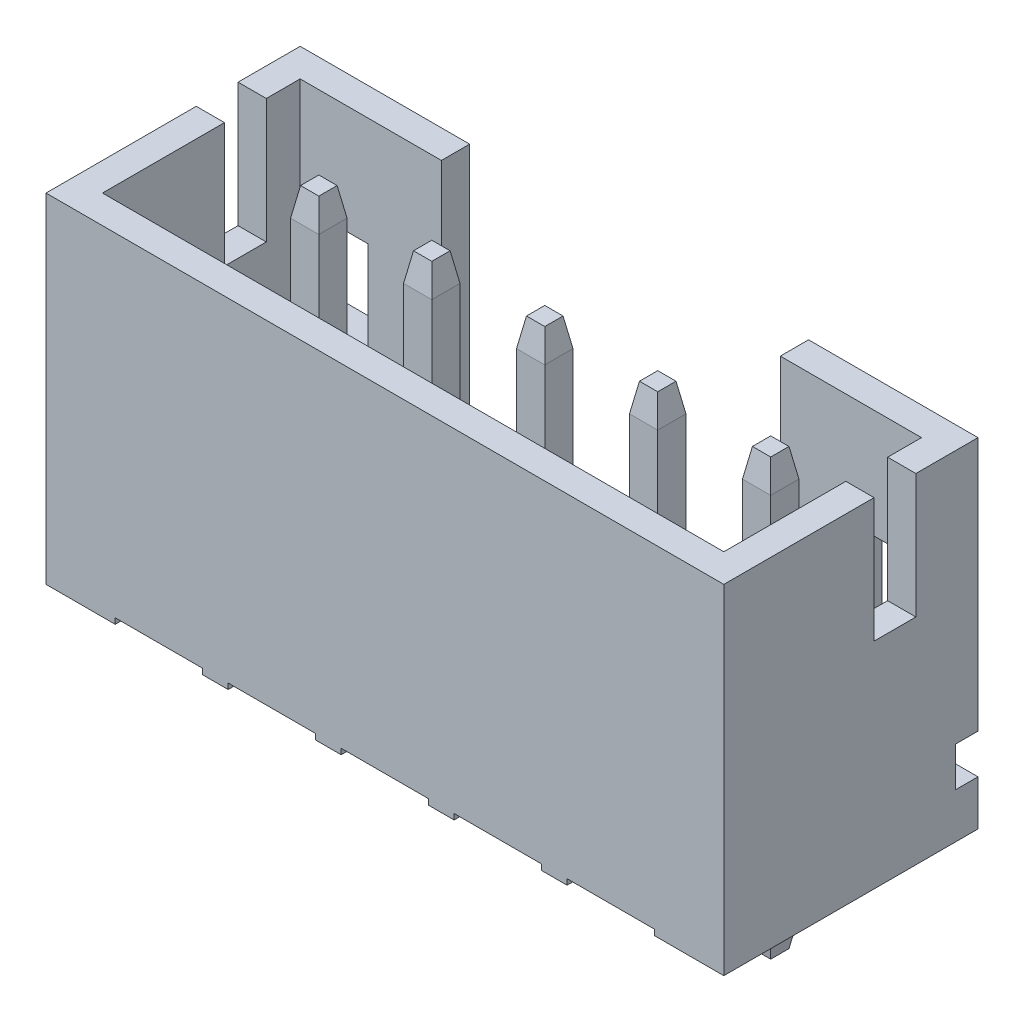
from build123d import *

# Parameters (mm, degrees)
SKETCH1_W               = 12
SKETCH1_H               = 4.5
EXTRUDE1_DEPTH          = 6
CUT_EXTRUDE1_DEPTH      = 5.5
SKETCH3_W               = 11
SKETCH3_H               = 3.5
CUT_EXTRUDE2_DEPTH      = 4.2
SKETCH5_W               = 0.74
SKETCH5_H               = 2.2
CUT_EXTRUDE3_DEPTH      = 13
SKETCH6_W               = 6
SKETCH6_H               = 4
CUT_EXTRUDE4_DEPTH      = 1.2
SKETCH9_W               = 0.4
SKETCH9_H               = 0.7
CUT_EXTRUDE5_DEPTH      = 7
CUT_EXTRUDE5_DEPTH_BACK = 7
SKETCH10_W              = 1.2
SKETCH10_H              = 1.6
CUT_EXTRUDE6_DEPTH      = 0.5
CUT_EXTRUDE7_START      = -5.5
CUT_EXTRUDE7_DEPTH      = 11
LPATTERN4_COUNT         = 3
LPATTERN4_PITCH         = 2
LPATTERN4_COL_COUNT     = 3
LPATTERN4_COL_PITCH     = 2
EXTRUDE2_START          = -2
EXTRUDE2_DEPTH          = 7.7
LPATTERN2_COUNT         = 3
LPATTERN2_PITCH         = 2
LPATTERN2_COL_COUNT     = 3
LPATTERN2_COL_PITCH     = 2
CHAMFER1_SIZE           = 0.5
CHAMFER1_SIZE2          = 0.08816349
CHAMFER1_PART_2_SIZE    = 0.5
CHAMFER1_PART_2_SIZE2   = 0.08816349
CHAMFER1_PART_3_SIZE    = 0.5
CHAMFER1_PART_3_SIZE2   = 0.08816349
CHAMFER1_PART_4_SIZE    = 0.5
CHAMFER1_PART_4_SIZE2   = 0.08816349
CHAMFER1_PART_5_SIZE    = 0.5
CHAMFER1_PART_5_SIZE2   = 0.08816349
CHAMFER1_PART_6_SIZE    = 0.5
CHAMFER1_PART_6_SIZE2   = 0.08816349
CHAMFER1_PART_7_SIZE    = 0.5
CHAMFER1_PART_7_SIZE2   = 0.08816349
CHAMFER1_PART_8_SIZE    = 0.5
CHAMFER1_PART_8_SIZE2   = 0.08816349
CHAMFER1_PART_9_SIZE    = 0.5
CHAMFER1_PART_9_SIZE2   = 0.08816349
CHAMFER1_PART_10_SIZE   = 0.5
CHAMFER1_PART_10_SIZE2  = 0.08816349
CHAMFER1_PART_11_SIZE   = 0.5
CHAMFER1_PART_11_SIZE2  = 0.08816349
CHAMFER1_PART_12_SIZE   = 0.5
CHAMFER1_PART_12_SIZE2  = 0.08816349
CHAMFER1_PART_13_SIZE   = 0.5
CHAMFER1_PART_13_SIZE2  = 0.08816349
CHAMFER1_PART_14_SIZE   = 0.5
CHAMFER1_PART_14_SIZE2  = 0.08816349
CHAMFER1_PART_15_SIZE   = 0.5
CHAMFER1_PART_15_SIZE2  = 0.08816349
CHAMFER1_PART_16_SIZE   = 0.5
CHAMFER1_PART_16_SIZE2  = 0.08816349
CHAMFER1_PART_17_SIZE   = 0.5
CHAMFER1_PART_17_SIZE2  = 0.08816349
CHAMFER1_PART_18_SIZE   = 0.5
CHAMFER1_PART_18_SIZE2  = 0.08816349
CHAMFER1_PART_19_SIZE   = 0.5
CHAMFER1_PART_19_SIZE2  = 0.08816349
CHAMFER1_PART_20_SIZE   = 0.5
CHAMFER1_PART_20_SIZE2  = 0.08816349
CHAMFER1_PART_21_SIZE   = 0.5
CHAMFER1_PART_21_SIZE2  = 0.08816349
CHAMFER1_PART_22_SIZE   = 0.5
CHAMFER1_PART_22_SIZE2  = 0.08816349
CHAMFER1_PART_23_SIZE   = 0.5
CHAMFER1_PART_23_SIZE2  = 0.08816349
CHAMFER1_PART_24_SIZE   = 0.5
CHAMFER1_PART_24_SIZE2  = 0.08816349
CHAMFER1_PART_25_SIZE   = 0.5
CHAMFER1_PART_25_SIZE2  = 0.08816349
CHAMFER1_PART_26_SIZE   = 0.5
CHAMFER1_PART_26_SIZE2  = 0.08816349
CHAMFER1_PART_27_SIZE   = 0.5
CHAMFER1_PART_27_SIZE2  = 0.08816349
CHAMFER1_PART_28_SIZE   = 0.5
CHAMFER1_PART_28_SIZE2  = 0.08816349
CHAMFER1_PART_29_SIZE   = 0.5
CHAMFER1_PART_29_SIZE2  = 0.08816349
CHAMFER1_PART_30_SIZE   = 0.5
CHAMFER1_PART_30_SIZE2  = 0.08816349
CHAMFER1_PART_31_SIZE   = 0.5
CHAMFER1_PART_31_SIZE2  = 0.08816349
CHAMFER1_PART_32_SIZE   = 0.5
CHAMFER1_PART_32_SIZE2  = 0.08816349
CHAMFER1_PART_33_SIZE   = 0.5
CHAMFER1_PART_33_SIZE2  = 0.08816349
CHAMFER1_PART_34_SIZE   = 0.5
CHAMFER1_PART_34_SIZE2  = 0.08816349
CHAMFER1_PART_35_SIZE   = 0.5
CHAMFER1_PART_35_SIZE2  = 0.08816349
CHAMFER1_PART_36_SIZE   = 0.5
CHAMFER1_PART_36_SIZE2  = 0.08816349
CHAMFER1_PART_37_SIZE   = 0.5
CHAMFER1_PART_37_SIZE2  = 0.08816349
CHAMFER1_PART_38_SIZE   = 0.5
CHAMFER1_PART_38_SIZE2  = 0.08816349
CHAMFER1_PART_39_SIZE   = 0.5
CHAMFER1_PART_39_SIZE2  = 0.08816349
CHAMFER1_PART_40_SIZE   = 0.5
CHAMFER1_PART_40_SIZE2  = 0.08816349


with BuildPart() as part:
    # Sketch1 → Extrude1 (new body)
    with BuildSketch(Plane(origin=(0, 0, 0), x_dir=(1, 0, 0), z_dir=(0, 1, 0))):
        Rectangle(SKETCH1_W, SKETCH1_H)
    extrude(amount=EXTRUDE1_DEPTH)

    # Sketch2 → Cut-Extrude1 (cut, through all)
    with BuildSketch(Plane.XY.offset(2.25)):
        Polygon((-0.775, 0.1), (0.775, 0.1), (0.775, 0), (0, 0), (-0.775, 0), align=None)
    cut_extrude1 = extrude(amount=-CUT_EXTRUDE1_DEPTH, mode=Mode.SUBTRACT)

    # Sketch3 → Cut-Extrude2 (cut)
    with BuildSketch(Plane(origin=(0, 6, 0), x_dir=(-1, 0, 0), z_dir=(0, 1, 0))):
        Rectangle(SKETCH3_W, SKETCH3_H)
    extrude(amount=-CUT_EXTRUDE2_DEPTH, mode=Mode.SUBTRACT)

    # Sketch5 → Cut-Extrude3 (cut, through all)
    with BuildSketch(Plane.ZY.offset(6)):
        with Locations((-0.78, 4.9)):
            Rectangle(SKETCH5_W, SKETCH5_H)
    extrude(amount=-CUT_EXTRUDE3_DEPTH, mode=Mode.SUBTRACT)

    # Sketch6 → Cut-Extrude4 (cut)
    with BuildSketch(Plane(origin=(0, 0, -2.25), x_dir=(-1, 0, 0), z_dir=(0, 0, -1))):
        with Locations((0, 4)):
            Rectangle(SKETCH6_W, SKETCH6_H)
    extrude(amount=-CUT_EXTRUDE4_DEPTH, mode=Mode.SUBTRACT)

    # Sketch9 → Cut-Extrude5 (cut, two sides)
    with BuildSketch(Plane(origin=(0, 0, 0), x_dir=(0, 0, -1), z_dir=(1, 0, 0))) as cut_extrude5_sk:
        with Locations((2.05, 1.15)):
            Rectangle(SKETCH9_W, SKETCH9_H)
    extrude(amount=CUT_EXTRUDE5_DEPTH, mode=Mode.SUBTRACT)
    extrude(cut_extrude5_sk.sketch, amount=-CUT_EXTRUDE5_DEPTH_BACK, mode=Mode.SUBTRACT)

    # Sketch10 → Cut-Extrude6 (cut)
    with BuildSketch(Plane(origin=(0, 0, -2.25), x_dir=(-1, 0, 0), z_dir=(0, 0, -1))):
        with Locations((-4.9, 3.271645398)):
            Rectangle(SKETCH10_W, SKETCH10_H)
        with Locations((4.9, 3.271645398)):
            Rectangle(SKETCH10_W, SKETCH10_H)
    extrude(amount=-CUT_EXTRUDE6_DEPTH, mode=Mode.SUBTRACT)

    # Sketch11 → Cut-Extrude7 (cut)
    with BuildSketch(Plane(origin=(0, 0, 0), x_dir=(0, 0, -1), z_dir=(1, 0, 0)).offset(CUT_EXTRUDE7_START)):
        Polygon((0, 1.8), (-0.576387184, 1.223612816), (-1.75, 1.223612816), (-1.75, 1.8), align=None)
    extrude(amount=CUT_EXTRUDE7_DEPTH, mode=Mode.SUBTRACT)

    # LPattern4: Cut-Extrude1 ×3
    with Locations(*[(i * LPATTERN4_PITCH, 0, 0) for i in range(1, LPATTERN4_COUNT)]):
        add(cut_extrude1, mode=Mode.SUBTRACT)

    # LPattern4 col: Cut-Extrude1 ×3
    with Locations(*[(-i * LPATTERN4_COL_PITCH, 0, 0) for i in range(1, LPATTERN4_COL_COUNT)]):
        add(cut_extrude1, mode=Mode.SUBTRACT)

    # Sketch7 → Extrude2 (add)
    with BuildSketch(Plane(origin=(0, 0, 0), x_dir=(1, 0, 0), z_dir=(0, 1, 0)).offset(EXTRUDE2_START)):
        Polygon((0, 0.33), (0.25, 0.33), (0.25, 0.83), (-0.25, 0.83), (-0.25, 0.33), align=None)
    extrude2 = extrude(amount=EXTRUDE2_DEPTH)

    # LPattern2: Extrude2 ×3
    with Locations(*[(i * LPATTERN2_PITCH, 0, 0) for i in range(1, LPATTERN2_COUNT)]):
        add(extrude2)

    # LPattern2 col: Extrude2 ×3
    with Locations(*[(-i * LPATTERN2_COL_PITCH, 0, 0) for i in range(1, LPATTERN2_COL_COUNT)]):
        add(extrude2)

    # Chamfer1
    chamfer1_edges = [part.edges().sort_by_distance(p)[0] for p in [
        (-0.25, -2, -0.58),
    ]]
    chamfer1_side = [part.faces().sort_by_distance(p)[0] for p in [
        (-0.25, -0.95, -0.58),
    ]]
    chamfer(chamfer1_edges, length=CHAMFER1_SIZE, length2=CHAMFER1_SIZE2, reference=chamfer1_side[0])

    # Chamfer1 part 2
    chamfer1_part_2_edges = [part.edges().sort_by_distance(p)[0] for p in [
        (0, -2, -0.33),
    ]]
    chamfer1_part_2_side = [part.faces().sort_by_distance(p)[0] for p in [
        (0, -0.95, -0.33),
    ]]
    chamfer(chamfer1_part_2_edges, length=CHAMFER1_PART_2_SIZE, length2=CHAMFER1_PART_2_SIZE2, reference=chamfer1_part_2_side[0])

    # Chamfer1 part 3
    chamfer1_part_3_edges = [part.edges().sort_by_distance(p)[0] for p in [
        (0.25, -2, -0.58),
    ]]
    chamfer1_part_3_side = [part.faces().sort_by_distance(p)[0] for p in [
        (0.25, -0.95, -0.58),
    ]]
    chamfer(chamfer1_part_3_edges, length=CHAMFER1_PART_3_SIZE, length2=CHAMFER1_PART_3_SIZE2, reference=chamfer1_part_3_side[0])

    # Chamfer1 part 4
    chamfer1_part_4_edges = [part.edges().sort_by_distance(p)[0] for p in [
        (0, -2, -0.83),
    ]]
    chamfer1_part_4_side = [part.faces().sort_by_distance(p)[0] for p in [
        (0, -0.95, -0.83),
    ]]
    chamfer(chamfer1_part_4_edges, length=CHAMFER1_PART_4_SIZE, length2=CHAMFER1_PART_4_SIZE2, reference=chamfer1_part_4_side[0])

    # Chamfer1 part 5
    chamfer1_part_5_edges = [part.edges().sort_by_distance(p)[0] for p in [
        (0, 5.7, -0.83),
    ]]
    chamfer1_part_5_side = [part.faces().sort_by_distance(p)[0] for p in [
        (0, 3.75, -0.83),
    ]]
    chamfer(chamfer1_part_5_edges, length=CHAMFER1_PART_5_SIZE, length2=CHAMFER1_PART_5_SIZE2, reference=chamfer1_part_5_side[0])

    # Chamfer1 part 6
    chamfer1_part_6_edges = [part.edges().sort_by_distance(p)[0] for p in [
        (-0.25, 5.7, -0.58),
    ]]
    chamfer1_part_6_side = [part.faces().sort_by_distance(p)[0] for p in [
        (-0.25, 3.75, -0.58),
    ]]
    chamfer(chamfer1_part_6_edges, length=CHAMFER1_PART_6_SIZE, length2=CHAMFER1_PART_6_SIZE2, reference=chamfer1_part_6_side[0])

    # Chamfer1 part 7
    chamfer1_part_7_edges = [part.edges().sort_by_distance(p)[0] for p in [
        (0, 5.7, -0.33),
    ]]
    chamfer1_part_7_side = [part.faces().sort_by_distance(p)[0] for p in [
        (0, 3.75, -0.33),
    ]]
    chamfer(chamfer1_part_7_edges, length=CHAMFER1_PART_7_SIZE, length2=CHAMFER1_PART_7_SIZE2, reference=chamfer1_part_7_side[0])

    # Chamfer1 part 8
    chamfer1_part_8_edges = [part.edges().sort_by_distance(p)[0] for p in [
        (0.25, 5.7, -0.58),
    ]]
    chamfer1_part_8_side = [part.faces().sort_by_distance(p)[0] for p in [
        (0.25, 3.75, -0.58),
    ]]
    chamfer(chamfer1_part_8_edges, length=CHAMFER1_PART_8_SIZE, length2=CHAMFER1_PART_8_SIZE2, reference=chamfer1_part_8_side[0])

    # Chamfer1 part 9
    chamfer1_part_9_edges = [part.edges().sort_by_distance(p)[0] for p in [
        (-2.25, -2, -0.58),
    ]]
    chamfer1_part_9_side = [part.faces().sort_by_distance(p)[0] for p in [
        (-2.25, -0.95, -0.58),
    ]]
    chamfer(chamfer1_part_9_edges, length=CHAMFER1_PART_9_SIZE, length2=CHAMFER1_PART_9_SIZE2, reference=chamfer1_part_9_side[0])

    # Chamfer1 part 10
    chamfer1_part_10_edges = [part.edges().sort_by_distance(p)[0] for p in [
        (-2, -2, -0.33),
    ]]
    chamfer1_part_10_side = [part.faces().sort_by_distance(p)[0] for p in [
        (-2, -0.95, -0.33),
    ]]
    chamfer(chamfer1_part_10_edges, length=CHAMFER1_PART_10_SIZE, length2=CHAMFER1_PART_10_SIZE2, reference=chamfer1_part_10_side[0])

    # Chamfer1 part 11
    chamfer1_part_11_edges = [part.edges().sort_by_distance(p)[0] for p in [
        (-1.75, -2, -0.58),
    ]]
    chamfer1_part_11_side = [part.faces().sort_by_distance(p)[0] for p in [
        (-1.75, -0.95, -0.58),
    ]]
    chamfer(chamfer1_part_11_edges, length=CHAMFER1_PART_11_SIZE, length2=CHAMFER1_PART_11_SIZE2, reference=chamfer1_part_11_side[0])

    # Chamfer1 part 12
    chamfer1_part_12_edges = [part.edges().sort_by_distance(p)[0] for p in [
        (-2, -2, -0.83),
    ]]
    chamfer1_part_12_side = [part.faces().sort_by_distance(p)[0] for p in [
        (-2, -0.95, -0.83),
    ]]
    chamfer(chamfer1_part_12_edges, length=CHAMFER1_PART_12_SIZE, length2=CHAMFER1_PART_12_SIZE2, reference=chamfer1_part_12_side[0])

    # Chamfer1 part 13
    chamfer1_part_13_edges = [part.edges().sort_by_distance(p)[0] for p in [
        (-2, 5.7, -0.83),
    ]]
    chamfer1_part_13_side = [part.faces().sort_by_distance(p)[0] for p in [
        (-2, 3.75, -0.83),
    ]]
    chamfer(chamfer1_part_13_edges, length=CHAMFER1_PART_13_SIZE, length2=CHAMFER1_PART_13_SIZE2, reference=chamfer1_part_13_side[0])

    # Chamfer1 part 14
    chamfer1_part_14_edges = [part.edges().sort_by_distance(p)[0] for p in [
        (-2.25, 5.7, -0.58),
    ]]
    chamfer1_part_14_side = [part.faces().sort_by_distance(p)[0] for p in [
        (-2.25, 3.75, -0.58),
    ]]
    chamfer(chamfer1_part_14_edges, length=CHAMFER1_PART_14_SIZE, length2=CHAMFER1_PART_14_SIZE2, reference=chamfer1_part_14_side[0])

    # Chamfer1 part 15
    chamfer1_part_15_edges = [part.edges().sort_by_distance(p)[0] for p in [
        (-2, 5.7, -0.33),
    ]]
    chamfer1_part_15_side = [part.faces().sort_by_distance(p)[0] for p in [
        (-2, 3.75, -0.33),
    ]]
    chamfer(chamfer1_part_15_edges, length=CHAMFER1_PART_15_SIZE, length2=CHAMFER1_PART_15_SIZE2, reference=chamfer1_part_15_side[0])

    # Chamfer1 part 16
    chamfer1_part_16_edges = [part.edges().sort_by_distance(p)[0] for p in [
        (-1.75, 5.7, -0.58),
    ]]
    chamfer1_part_16_side = [part.faces().sort_by_distance(p)[0] for p in [
        (-1.75, 3.75, -0.58),
    ]]
    chamfer(chamfer1_part_16_edges, length=CHAMFER1_PART_16_SIZE, length2=CHAMFER1_PART_16_SIZE2, reference=chamfer1_part_16_side[0])

    # Chamfer1 part 17
    chamfer1_part_17_edges = [part.edges().sort_by_distance(p)[0] for p in [
        (-4.25, -2, -0.58),
    ]]
    chamfer1_part_17_side = [part.faces().sort_by_distance(p)[0] for p in [
        (-4.25, -0.95, -0.58),
    ]]
    chamfer(chamfer1_part_17_edges, length=CHAMFER1_PART_17_SIZE, length2=CHAMFER1_PART_17_SIZE2, reference=chamfer1_part_17_side[0])

    # Chamfer1 part 18
    chamfer1_part_18_edges = [part.edges().sort_by_distance(p)[0] for p in [
        (-4, -2, -0.33),
    ]]
    chamfer1_part_18_side = [part.faces().sort_by_distance(p)[0] for p in [
        (-4, -0.95, -0.33),
    ]]
    chamfer(chamfer1_part_18_edges, length=CHAMFER1_PART_18_SIZE, length2=CHAMFER1_PART_18_SIZE2, reference=chamfer1_part_18_side[0])

    # Chamfer1 part 19
    chamfer1_part_19_edges = [part.edges().sort_by_distance(p)[0] for p in [
        (-3.75, -2, -0.58),
    ]]
    chamfer1_part_19_side = [part.faces().sort_by_distance(p)[0] for p in [
        (-3.75, -0.95, -0.58),
    ]]
    chamfer(chamfer1_part_19_edges, length=CHAMFER1_PART_19_SIZE, length2=CHAMFER1_PART_19_SIZE2, reference=chamfer1_part_19_side[0])

    # Chamfer1 part 20
    chamfer1_part_20_edges = [part.edges().sort_by_distance(p)[0] for p in [
        (-4, -2, -0.83),
    ]]
    chamfer1_part_20_side = [part.faces().sort_by_distance(p)[0] for p in [
        (-4, -0.95, -0.83),
    ]]
    chamfer(chamfer1_part_20_edges, length=CHAMFER1_PART_20_SIZE, length2=CHAMFER1_PART_20_SIZE2, reference=chamfer1_part_20_side[0])

    # Chamfer1 part 21
    chamfer1_part_21_edges = [part.edges().sort_by_distance(p)[0] for p in [
        (-4, 5.7, -0.83),
    ]]
    chamfer1_part_21_side = [part.faces().sort_by_distance(p)[0] for p in [
        (-4, 3.75, -0.83),
    ]]
    chamfer(chamfer1_part_21_edges, length=CHAMFER1_PART_21_SIZE, length2=CHAMFER1_PART_21_SIZE2, reference=chamfer1_part_21_side[0])

    # Chamfer1 part 22
    chamfer1_part_22_edges = [part.edges().sort_by_distance(p)[0] for p in [
        (-4.25, 5.7, -0.58),
    ]]
    chamfer1_part_22_side = [part.faces().sort_by_distance(p)[0] for p in [
        (-4.25, 3.75, -0.58),
    ]]
    chamfer(chamfer1_part_22_edges, length=CHAMFER1_PART_22_SIZE, length2=CHAMFER1_PART_22_SIZE2, reference=chamfer1_part_22_side[0])

    # Chamfer1 part 23
    chamfer1_part_23_edges = [part.edges().sort_by_distance(p)[0] for p in [
        (-4, 5.7, -0.33),
    ]]
    chamfer1_part_23_side = [part.faces().sort_by_distance(p)[0] for p in [
        (-4, 3.75, -0.33),
    ]]
    chamfer(chamfer1_part_23_edges, length=CHAMFER1_PART_23_SIZE, length2=CHAMFER1_PART_23_SIZE2, reference=chamfer1_part_23_side[0])

    # Chamfer1 part 24
    chamfer1_part_24_edges = [part.edges().sort_by_distance(p)[0] for p in [
        (-3.75, 5.7, -0.58),
    ]]
    chamfer1_part_24_side = [part.faces().sort_by_distance(p)[0] for p in [
        (-3.75, 3.75, -0.58),
    ]]
    chamfer(chamfer1_part_24_edges, length=CHAMFER1_PART_24_SIZE, length2=CHAMFER1_PART_24_SIZE2, reference=chamfer1_part_24_side[0])

    # Chamfer1 part 25
    chamfer1_part_25_edges = [part.edges().sort_by_distance(p)[0] for p in [
        (1.75, -2, -0.58),
    ]]
    chamfer1_part_25_side = [part.faces().sort_by_distance(p)[0] for p in [
        (1.75, -0.95, -0.58),
    ]]
    chamfer(chamfer1_part_25_edges, length=CHAMFER1_PART_25_SIZE, length2=CHAMFER1_PART_25_SIZE2, reference=chamfer1_part_25_side[0])

    # Chamfer1 part 26
    chamfer1_part_26_edges = [part.edges().sort_by_distance(p)[0] for p in [
        (2, -2, -0.33),
    ]]
    chamfer1_part_26_side = [part.faces().sort_by_distance(p)[0] for p in [
        (2, -0.95, -0.33),
    ]]
    chamfer(chamfer1_part_26_edges, length=CHAMFER1_PART_26_SIZE, length2=CHAMFER1_PART_26_SIZE2, reference=chamfer1_part_26_side[0])

    # Chamfer1 part 27
    chamfer1_part_27_edges = [part.edges().sort_by_distance(p)[0] for p in [
        (2.25, -2, -0.58),
    ]]
    chamfer1_part_27_side = [part.faces().sort_by_distance(p)[0] for p in [
        (2.25, -0.95, -0.58),
    ]]
    chamfer(chamfer1_part_27_edges, length=CHAMFER1_PART_27_SIZE, length2=CHAMFER1_PART_27_SIZE2, reference=chamfer1_part_27_side[0])

    # Chamfer1 part 28
    chamfer1_part_28_edges = [part.edges().sort_by_distance(p)[0] for p in [
        (2, -2, -0.83),
    ]]
    chamfer1_part_28_side = [part.faces().sort_by_distance(p)[0] for p in [
        (2, -0.95, -0.83),
    ]]
    chamfer(chamfer1_part_28_edges, length=CHAMFER1_PART_28_SIZE, length2=CHAMFER1_PART_28_SIZE2, reference=chamfer1_part_28_side[0])

    # Chamfer1 part 29
    chamfer1_part_29_edges = [part.edges().sort_by_distance(p)[0] for p in [
        (2, 5.7, -0.83),
    ]]
    chamfer1_part_29_side = [part.faces().sort_by_distance(p)[0] for p in [
        (2, 3.75, -0.83),
    ]]
    chamfer(chamfer1_part_29_edges, length=CHAMFER1_PART_29_SIZE, length2=CHAMFER1_PART_29_SIZE2, reference=chamfer1_part_29_side[0])

    # Chamfer1 part 30
    chamfer1_part_30_edges = [part.edges().sort_by_distance(p)[0] for p in [
        (1.75, 5.7, -0.58),
    ]]
    chamfer1_part_30_side = [part.faces().sort_by_distance(p)[0] for p in [
        (1.75, 3.75, -0.58),
    ]]
    chamfer(chamfer1_part_30_edges, length=CHAMFER1_PART_30_SIZE, length2=CHAMFER1_PART_30_SIZE2, reference=chamfer1_part_30_side[0])

    # Chamfer1 part 31
    chamfer1_part_31_edges = [part.edges().sort_by_distance(p)[0] for p in [
        (2, 5.7, -0.33),
    ]]
    chamfer1_part_31_side = [part.faces().sort_by_distance(p)[0] for p in [
        (2, 3.75, -0.33),
    ]]
    chamfer(chamfer1_part_31_edges, length=CHAMFER1_PART_31_SIZE, length2=CHAMFER1_PART_31_SIZE2, reference=chamfer1_part_31_side[0])

    # Chamfer1 part 32
    chamfer1_part_32_edges = [part.edges().sort_by_distance(p)[0] for p in [
        (2.25, 5.7, -0.58),
    ]]
    chamfer1_part_32_side = [part.faces().sort_by_distance(p)[0] for p in [
        (2.25, 3.75, -0.58),
    ]]
    chamfer(chamfer1_part_32_edges, length=CHAMFER1_PART_32_SIZE, length2=CHAMFER1_PART_32_SIZE2, reference=chamfer1_part_32_side[0])

    # Chamfer1 part 33
    chamfer1_part_33_edges = [part.edges().sort_by_distance(p)[0] for p in [
        (3.75, -2, -0.58),
    ]]
    chamfer1_part_33_side = [part.faces().sort_by_distance(p)[0] for p in [
        (3.75, -0.95, -0.58),
    ]]
    chamfer(chamfer1_part_33_edges, length=CHAMFER1_PART_33_SIZE, length2=CHAMFER1_PART_33_SIZE2, reference=chamfer1_part_33_side[0])

    # Chamfer1 part 34
    chamfer1_part_34_edges = [part.edges().sort_by_distance(p)[0] for p in [
        (4, -2, -0.33),
    ]]
    chamfer1_part_34_side = [part.faces().sort_by_distance(p)[0] for p in [
        (4, -0.95, -0.33),
    ]]
    chamfer(chamfer1_part_34_edges, length=CHAMFER1_PART_34_SIZE, length2=CHAMFER1_PART_34_SIZE2, reference=chamfer1_part_34_side[0])

    # Chamfer1 part 35
    chamfer1_part_35_edges = [part.edges().sort_by_distance(p)[0] for p in [
        (4.25, -2, -0.58),
    ]]
    chamfer1_part_35_side = [part.faces().sort_by_distance(p)[0] for p in [
        (4.25, -0.95, -0.58),
    ]]
    chamfer(chamfer1_part_35_edges, length=CHAMFER1_PART_35_SIZE, length2=CHAMFER1_PART_35_SIZE2, reference=chamfer1_part_35_side[0])

    # Chamfer1 part 36
    chamfer1_part_36_edges = [part.edges().sort_by_distance(p)[0] for p in [
        (4, -2, -0.83),
    ]]
    chamfer1_part_36_side = [part.faces().sort_by_distance(p)[0] for p in [
        (4, -0.95, -0.83),
    ]]
    chamfer(chamfer1_part_36_edges, length=CHAMFER1_PART_36_SIZE, length2=CHAMFER1_PART_36_SIZE2, reference=chamfer1_part_36_side[0])

    # Chamfer1 part 37
    chamfer1_part_37_edges = [part.edges().sort_by_distance(p)[0] for p in [
        (4, 5.7, -0.83),
    ]]
    chamfer1_part_37_side = [part.faces().sort_by_distance(p)[0] for p in [
        (4, 3.75, -0.83),
    ]]
    chamfer(chamfer1_part_37_edges, length=CHAMFER1_PART_37_SIZE, length2=CHAMFER1_PART_37_SIZE2, reference=chamfer1_part_37_side[0])

    # Chamfer1 part 38
    chamfer1_part_38_edges = [part.edges().sort_by_distance(p)[0] for p in [
        (3.75, 5.7, -0.58),
    ]]
    chamfer1_part_38_side = [part.faces().sort_by_distance(p)[0] for p in [
        (3.75, 3.75, -0.58),
    ]]
    chamfer(chamfer1_part_38_edges, length=CHAMFER1_PART_38_SIZE, length2=CHAMFER1_PART_38_SIZE2, reference=chamfer1_part_38_side[0])

    # Chamfer1 part 39
    chamfer1_part_39_edges = [part.edges().sort_by_distance(p)[0] for p in [
        (4, 5.7, -0.33),
    ]]
    chamfer1_part_39_side = [part.faces().sort_by_distance(p)[0] for p in [
        (4, 3.75, -0.33),
    ]]
    chamfer(chamfer1_part_39_edges, length=CHAMFER1_PART_39_SIZE, length2=CHAMFER1_PART_39_SIZE2, reference=chamfer1_part_39_side[0])

    # Chamfer1 part 40
    chamfer1_part_40_edges = [part.edges().sort_by_distance(p)[0] for p in [
        (4.25, 5.7, -0.58),
    ]]
    chamfer1_part_40_side = [part.faces().sort_by_distance(p)[0] for p in [
        (4.25, 3.75, -0.58),
    ]]
    chamfer(chamfer1_part_40_edges, length=CHAMFER1_PART_40_SIZE, length2=CHAMFER1_PART_40_SIZE2, reference=chamfer1_part_40_side[0])


solid = part.part
